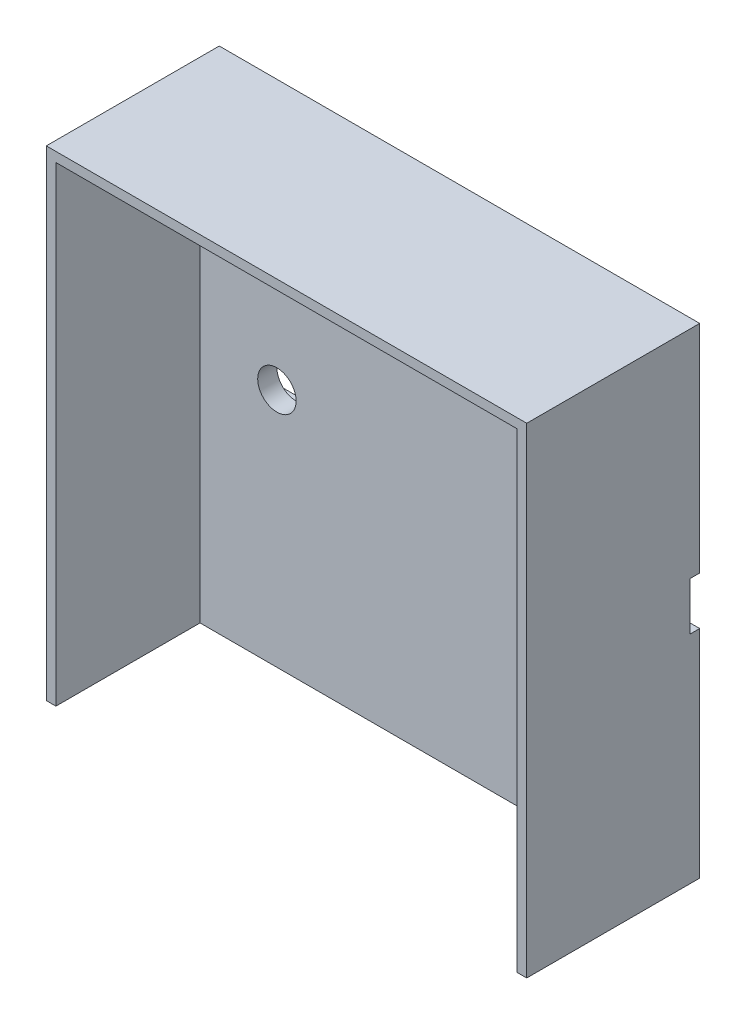
from build123d import *

# Parameters (mm, degrees)
SKICA1_W                 = 50
SKICA1_H                 = 50
P_IDAT_VYSUNUT_M2_DEPTH  = 3
SKICA5_W                 = 50
SKICA5_H                 = 5
ODEBRAT_VYSUNUT_M3_DEPTH = 1
P_IDAT_VYSUNUT_M9_DEPTH  = 15
SKICA17_R                = 2
ODEBRAT_VYSUNUT_M8_DEPTH = 4


with BuildPart() as part:
    # Skica1 → Přidat vysunutím2 (new body)
    with BuildSketch(Plane.XY):
        Rectangle(SKICA1_W, SKICA1_H)
    extrude(amount=P_IDAT_VYSUNUT_M2_DEPTH)

    # Skica5 → Odebrat vysunutím3 (cut)
    with BuildSketch(Plane(origin=(0, 0, 0), x_dir=(-1, 0, 0), z_dir=(0, 0, -1))):
        Rectangle(SKICA5_W, SKICA5_H)
    extrude(amount=-ODEBRAT_VYSUNUT_M3_DEPTH, mode=Mode.SUBTRACT)

    # Skica14 → Přidat vysunutím9 (add)
    with BuildSketch(Plane.XY.offset(3)):
        Polygon((25, 25), (-25, 25), (-25, -25), (-24, -25), (-24, 24), (24, 24), (24, -25), (25, -25), align=None)
    extrude(amount=P_IDAT_VYSUNUT_M9_DEPTH)

    # Skica17 → Odebrat vysunutím8 (cut)
    with BuildSketch(Plane(origin=(0, 0, 1), x_dir=(-1, 0, 0), z_dir=(0, 0, -1))):
        with Locations((-16, 0)):
            Circle(SKICA17_R)
        with Locations((16, 0)):
            Circle(SKICA17_R)
    extrude(amount=-ODEBRAT_VYSUNUT_M8_DEPTH, mode=Mode.SUBTRACT)


solid = part.part
